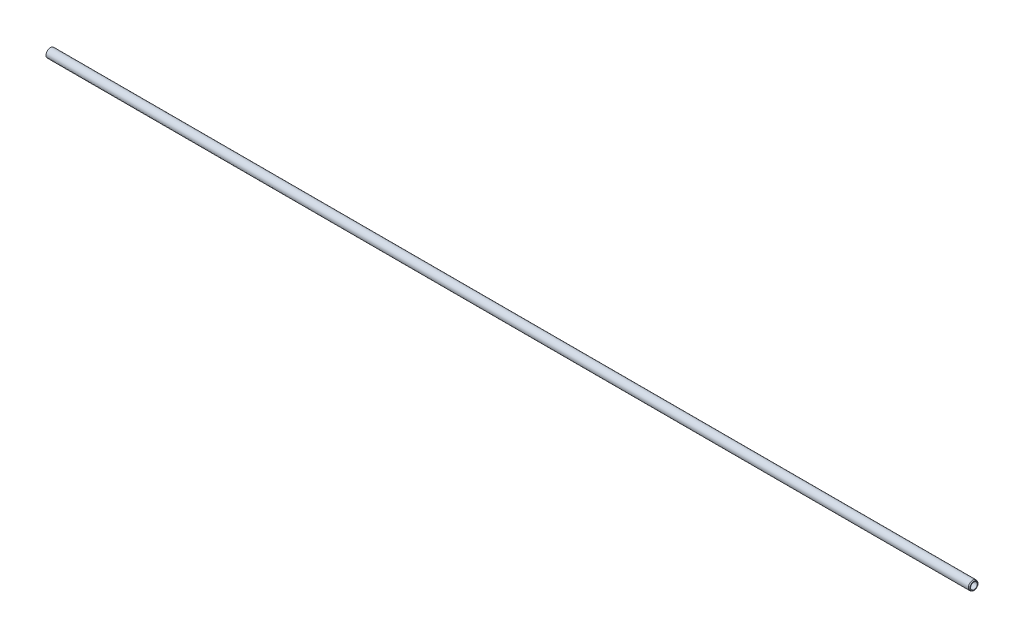
from build123d import *


with BuildPart() as part:
    # Sketch1 → Base-Revolve (revolve)
    with BuildSketch(Plane.XY):
        Polygon((0, 10), (0, 7.5), (2073, 7.5), (2073, 9.090074414), (2070.5, 10), align=None)
    revolve(axis=Axis((0, 0, 0), (1, 0, 0)))


solid = part.part
